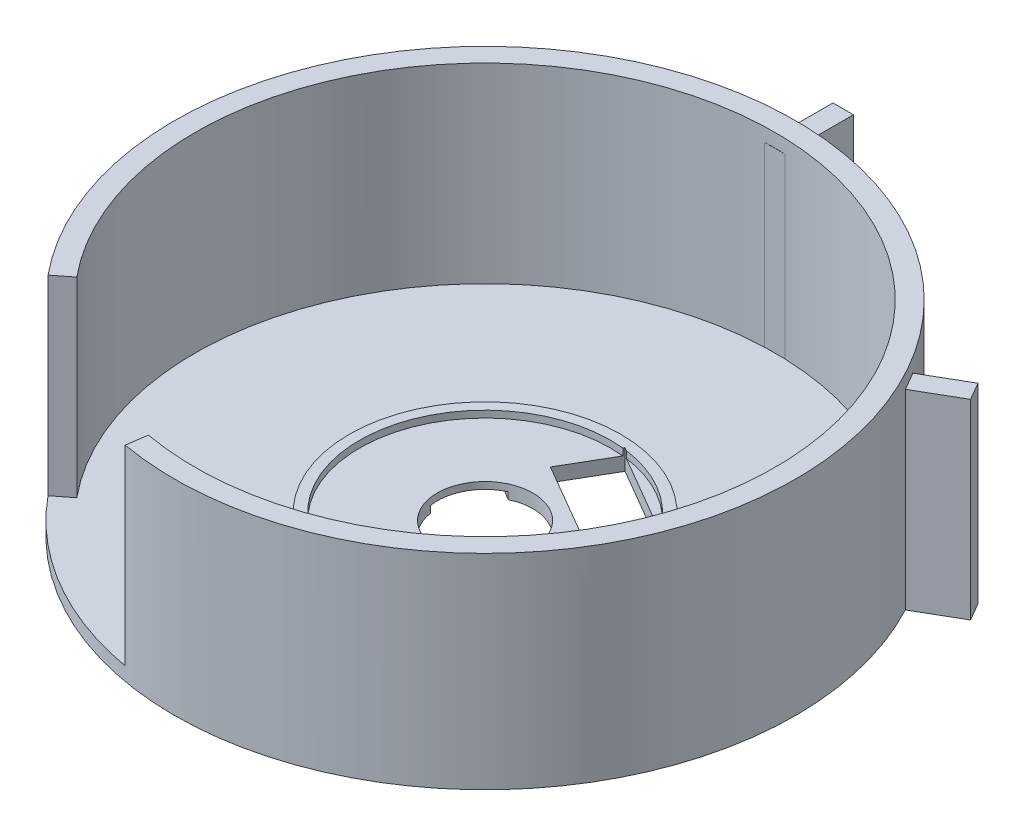
from build123d import *

# Parameters (mm, degrees)
SKETCH1_R                = 45.5
SKETCH1_R_2              = 42.5
BOSS_EXTRUDE1_DEPTH      = 30
SKETCH2_R                = 45.5
BOSS_EXTRUDE2_DEPTH      = 2
SKETCH3_R                = 7
CUT_EXTRUDE1_DEPTH       = 2
SKETCH7_W                = 3
SKETCH7_H                = 10
BOSS_EXTRUDE4_DEPTH      = 26
BOSS_EXTRUDE4_DEPTH_BACK = 2
SKETCH8_R                = 19.890165718
SKETCH8_R_2              = 18.390165718
BOSS_EXTRUDE5_DEPTH      = 1
CUT_EXTRUDE4_DEPTH       = 5.5
CUT_EXTRUDE5_DEPTH       = 58.5
CUT_EXTRUDE6_DEPTH       = 1


with BuildPart() as part:
    # Sketch1 → Boss-Extrude1 (new body)
    with BuildSketch(Plane(origin=(0, 0, 0), x_dir=(1, 0, 0), z_dir=(0, 1, 0))):
        Circle(SKETCH1_R)
        Circle(SKETCH1_R_2, mode=Mode.SUBTRACT)
    extrude(amount=BOSS_EXTRUDE1_DEPTH)

    # Sketch2 → Boss-Extrude2 (add)
    with BuildSketch(Plane.XZ):
        Circle(SKETCH2_R)
    extrude(amount=-BOSS_EXTRUDE2_DEPTH)

    # Sketch3 → Cut-Extrude1 (cut)
    with BuildSketch(Plane(origin=(0, 2, 0), x_dir=(1, 0, 0), z_dir=(0, 1, 0))):
        Circle(SKETCH3_R)
    extrude(amount=-CUT_EXTRUDE1_DEPTH, mode=Mode.SUBTRACT)

    # Sketch7 → Boss-Extrude4 (add, two sides)
    with BuildSketch(Plane(origin=(0, 2, 0), x_dir=(1, 0, 0), z_dir=(0, 1, 0))) as boss_extrude4_sk:
        with Locations((0, 47.473521163)):
            Rectangle(SKETCH7_W, SKETCH7_H)
        Polygon((46.193402353, 24.937722476), (37.533148315, 19.937722476), (36.033148315, 22.535798687), (44.693402353, 27.535798687), align=None)
    extrude(amount=BOSS_EXTRUDE4_DEPTH)
    extrude(boss_extrude4_sk.sketch, amount=-BOSS_EXTRUDE4_DEPTH_BACK)

    # Sketch8 → Boss-Extrude5 (add)
    with BuildSketch(Plane(origin=(0, 2, 0), x_dir=(1, 0, 0), z_dir=(0, 1, 0))):
        Circle(SKETCH8_R)
        Circle(SKETCH8_R_2, mode=Mode.SUBTRACT)
    extrude(amount=BOSS_EXTRUDE5_DEPTH)

    # Sketch10 → Cut-Extrude4 (cut)
    with BuildSketch(Plane.XZ):
        Polygon((2.016687189, -18.494703278), (14.981867268, -10.951222284), (10.958677405, -4.036459575), (-2.006502675, -11.579940569), align=None)
    extrude(amount=-CUT_EXTRUDE4_DEPTH, mode=Mode.SUBTRACT)

    # Sketch11 → Cut-Extrude5 (cut)
    with BuildSketch(Plane(origin=(0, 2, 0), x_dir=(1, 0, 0), z_dir=(0, 1, 0))):
        Polygon((-32.606600292, -26.874098434), (-35.165226496, -28.87311631), (-33.824988888, -37.754161376), (-11.7382848, -48.772412552), (-7.925983096, -44.804338986), (-7.495155029, -41.738838001), (-9.978475631, -35.419229659), (-25.965270809, -26.874098434), align=None)
    extrude(amount=CUT_EXTRUDE5_DEPTH, mode=Mode.SUBTRACT)

    # Sketch12 → Cut-Extrude6 (cut)
    with BuildSketch(Plane.XZ):
        Polygon((-6.912265346, 1.104802147), (-24.20763883, -9.480307189), (-19.814483018, -16.658435267), (-2.519109534, -6.073325931), align=None)
    extrude(amount=-CUT_EXTRUDE6_DEPTH, mode=Mode.SUBTRACT)


solid = part.part
